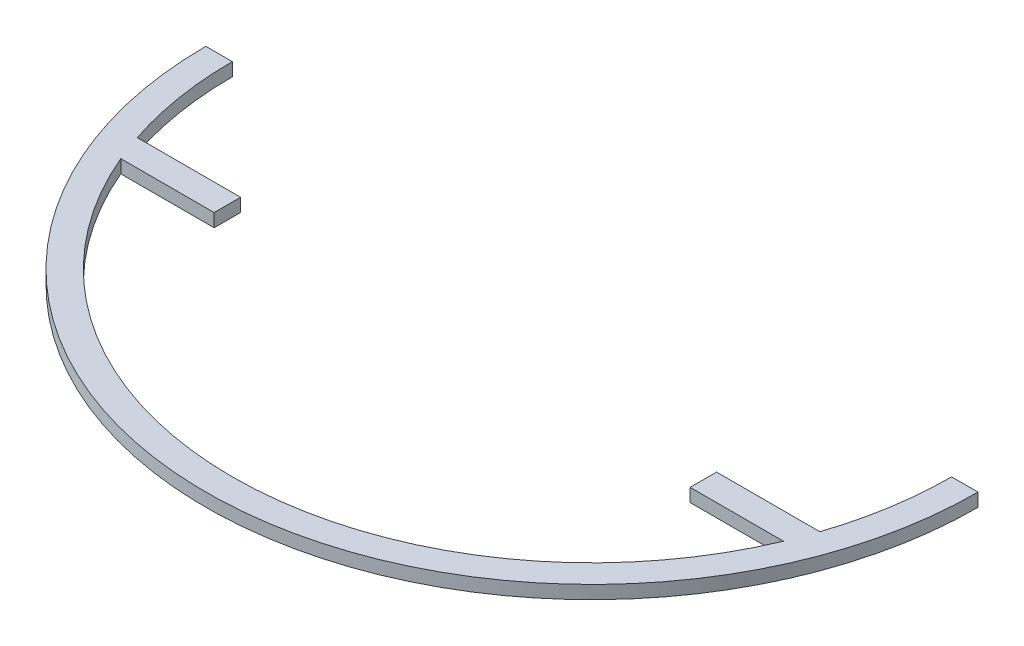
from build123d import *

# Parameters (mm, degrees)
BOSS_EXTRUDE1_DEPTH = 3.175


with BuildPart() as part:
    # Sketch1 → Boss-Extrude1 (new body)
    with BuildSketch(Plane(origin=(0, 0, 0), x_dir=(1, 0, 0), z_dir=(0, 1, 0))):
        with BuildLine():
            Line((-57.15, -27.220431682), (-81.957901993, -27.220431682))
            ThreePointArc((-81.957901993, -27.220431682), (-80.82536417, -30.418910347), (-79.568057138, -33.570431682))
            Line((-79.568057138, -33.570431682), (-57.15, -33.570431682))
            Line((-57.15, -33.570431682), (-57.15, -27.220431682))
        make_face()
        with BuildLine():
            Line((-86.36, 0), (-92.71, 0))
            ThreePointArc((-92.71, 0), (0, -92.71), (92.71, 0))
            Line((92.71, 0), (86.36, 0))
            ThreePointArc((86.36, 0), (85.252372448, -13.787044351), (81.957901993, -27.220431682))
            Line((81.957901993, -27.220431682), (81.957901993, -33.570431682))
            Line((81.957901993, -33.570431682), (79.568057138, -33.570431682))
            ThreePointArc((79.568057138, -33.570431682), (0, -86.36), (-79.568057138, -33.570431682))
            Line((-79.568057138, -33.570431682), (-81.957901993, -33.570431682))
            Line((-81.957901993, -33.570431682), (-81.957901993, -27.220431682))
            ThreePointArc((-81.957901993, -27.220431682), (-85.252372448, -13.787044351), (-86.36, 0))
        make_face()
        with BuildLine():
            ThreePointArc((-79.568057138, -33.570431682), (-80.82536417, -30.418910347), (-81.957901993, -27.220431682))
            Line((-81.957901993, -27.220431682), (-81.957901993, -33.570431682))
            Line((-81.957901993, -33.570431682), (-79.568057138, -33.570431682))
        make_face()
        with BuildLine():
            Line((81.957901993, -33.570431682), (81.957901993, -27.220431682))
            ThreePointArc((81.957901993, -27.220431682), (80.82536417, -30.418910347), (79.568057138, -33.570431682))
            Line((79.568057138, -33.570431682), (81.957901993, -33.570431682))
        make_face()
        with BuildLine():
            ThreePointArc((79.568057138, -33.570431682), (80.82536417, -30.418910347), (81.957901993, -27.220431682))
            Line((81.957901993, -27.220431682), (57.15, -27.220431682))
            Line((57.15, -27.220431682), (57.15, -33.570431682))
            Line((57.15, -33.570431682), (79.568057138, -33.570431682))
        make_face()
    extrude(amount=BOSS_EXTRUDE1_DEPTH)


solid = part.part
